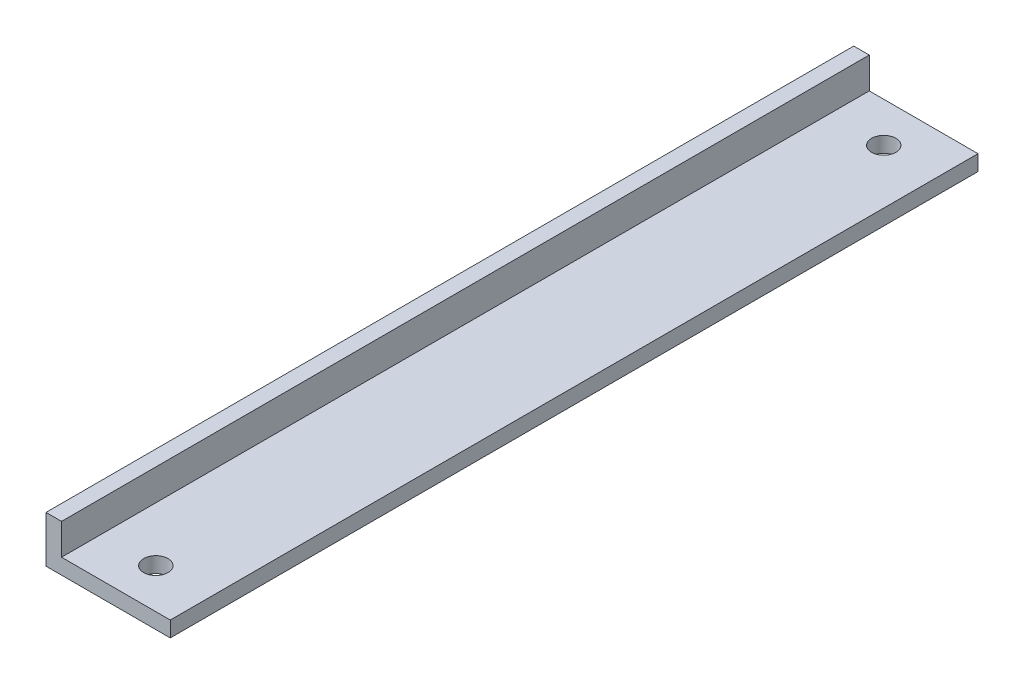
from build123d import *

# Parameters (mm, degrees)
BOSS_EXTRUDE1_DEPTH = 82.55
SKETCH2_R           = 2.4892
CUT_EXTRUDE4_DEPTH  = 10.525


with BuildPart() as part:
    # Sketch1 → Boss-Extrude1 (new body, symmetric)
    with BuildSketch(Plane.XY):
        Polygon((0, 9.525), (0, 0), (25.4, 0), (25.4, 3.175), (3.175, 3.175), (3.175, 9.525), align=None)
    extrude(amount=BOSS_EXTRUDE1_DEPTH, both=True)

    # Sketch2 → Cut-Extrude4 (cut, through all)
    with BuildSketch(Plane(origin=(0, 0, 0), x_dir=(1, 0, 0), z_dir=(0, 1, 0))):
        with Locations((14.2875, -74.3926249)):
            Circle(SKETCH2_R)
        with Locations((14.2875, 74.3926249)):
            Circle(SKETCH2_R)
    extrude(amount=CUT_EXTRUDE4_DEPTH, mode=Mode.SUBTRACT)


solid = part.part
